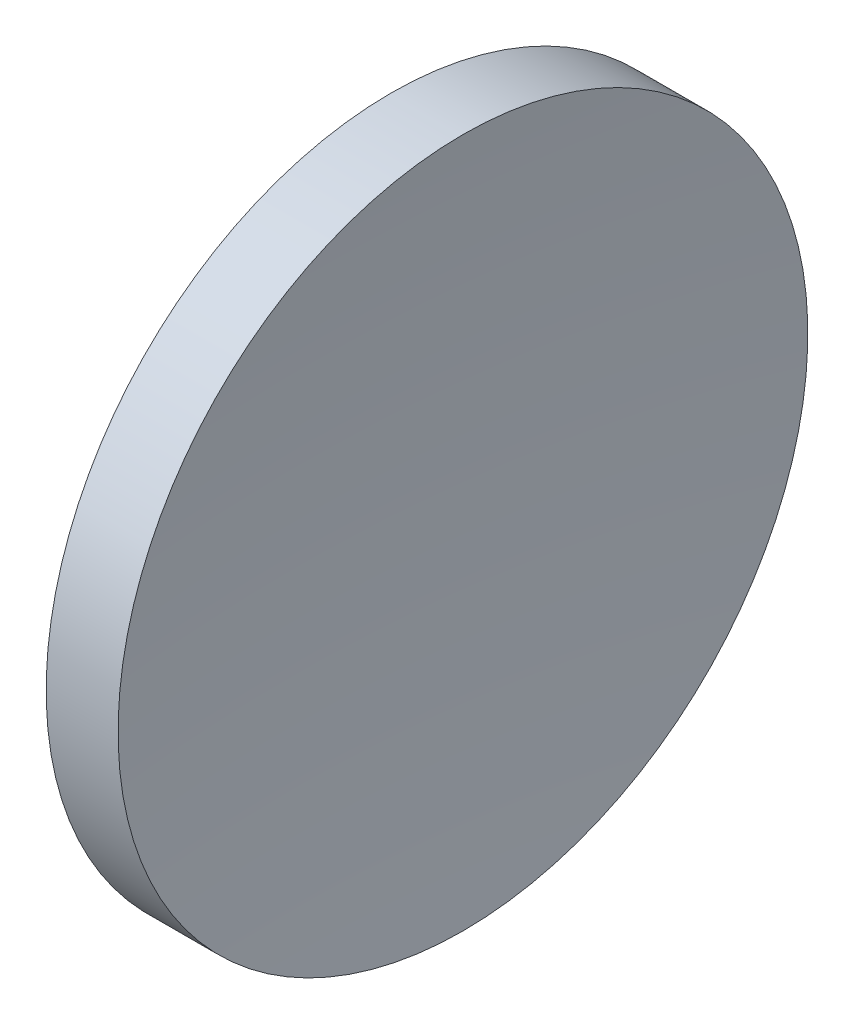
from build123d import *


with BuildPart() as part:
    # 草图1 → 旋转1 (revolve)
    with BuildSketch(Plane.XY, mode=Mode.PRIVATE) as revolve_1_sk:
        with BuildLine():
            Line((57.358190158, 32.578725913), (57.358190158, 45.078725913))
            Line((57.358190158, 45.078725913), (59.964624645, 45.078725913))
            ThreePointArc((59.964624645, 45.078725913), (59.509887953, 38.836076844), (59.35819028, 32.578725913))
            Line((59.35819028, 32.578725913), (57.358190158, 32.578725913))
        make_face()
    revolve(revolve_1_sk.sketch.rotate(Axis((55.007394624, 32.578725913, 0), (1, 0, 0)), 180), axis=Axis((55.007394624, 32.578725913, 0), (1, 0, 0)))  # turned: the seam where the file's is


solid = part.part
